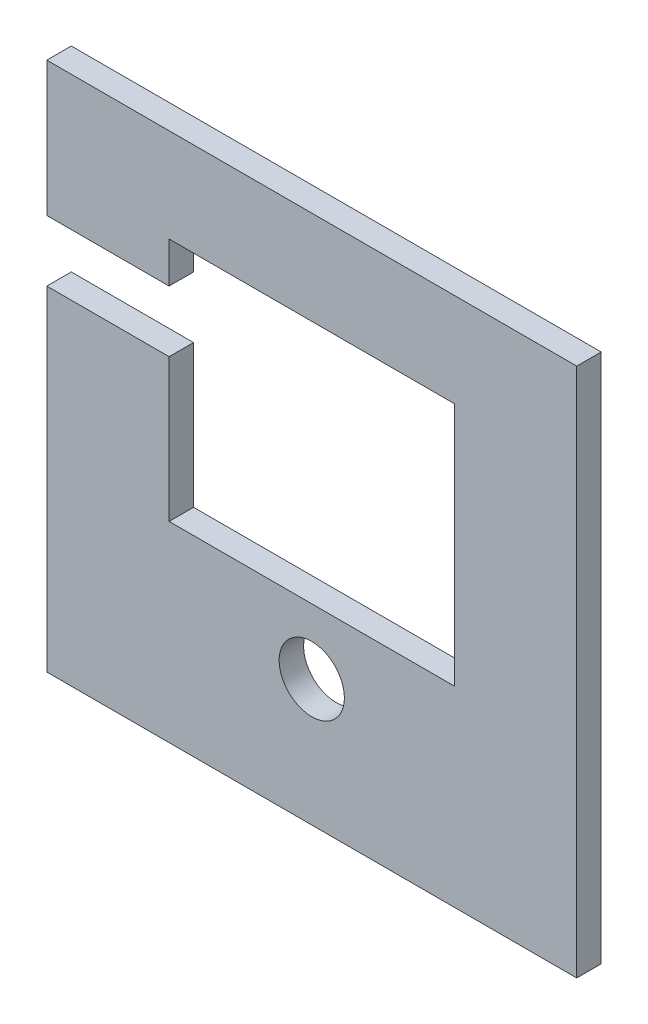
from build123d import *

# Parameters (mm, degrees)
SCHIZZO1_W                   = 130
SCHIZZO1_H                   = 130
ESTRUSIONE_ESTRUSIONE1_DEPTH = 6
SCHIZZO2_W                   = 70
SCHIZZO2_H                   = 60
TAGLIO_ESTRUSIONE1_DEPTH     = 15
SCHIZZO3_R                   = 8
TAGLIO_ESTRUSIONE2_DEPTH     = 15
SCHIZZO4_W                   = 30
SCHIZZO4_H                   = 15
TAGLIO_ESTRUSIONE3_DEPTH     = 15


with BuildPart() as part:
    # Schizzo1 → Estrusione-Estrusione1 (new body)
    with BuildSketch(Plane.XY):
        Rectangle(SCHIZZO1_W, SCHIZZO1_H)
    extrude(amount=ESTRUSIONE_ESTRUSIONE1_DEPTH)

    # Schizzo2 → Taglio-Estrusione1 (cut)
    with BuildSketch(Plane.XY.offset(6)):
        with Locations((0, 12)):
            Rectangle(SCHIZZO2_W, SCHIZZO2_H)
    extrude(amount=-TAGLIO_ESTRUSIONE1_DEPTH, mode=Mode.SUBTRACT)

    # Schizzo3 → Taglio-Estrusione2 (cut)
    with BuildSketch(Plane.XY.offset(6)):
        with Locations((0, -34)):
            Circle(SCHIZZO3_R)
    extrude(amount=-TAGLIO_ESTRUSIONE2_DEPTH, mode=Mode.SUBTRACT)

    # Schizzo4 → Taglio-Estrusione3 (cut)
    with BuildSketch(Plane.XY.offset(6)):
        with Locations((-50, 24.5)):
            Rectangle(SCHIZZO4_W, SCHIZZO4_H)
    extrude(amount=-TAGLIO_ESTRUSIONE3_DEPTH, mode=Mode.SUBTRACT)


solid = part.part
